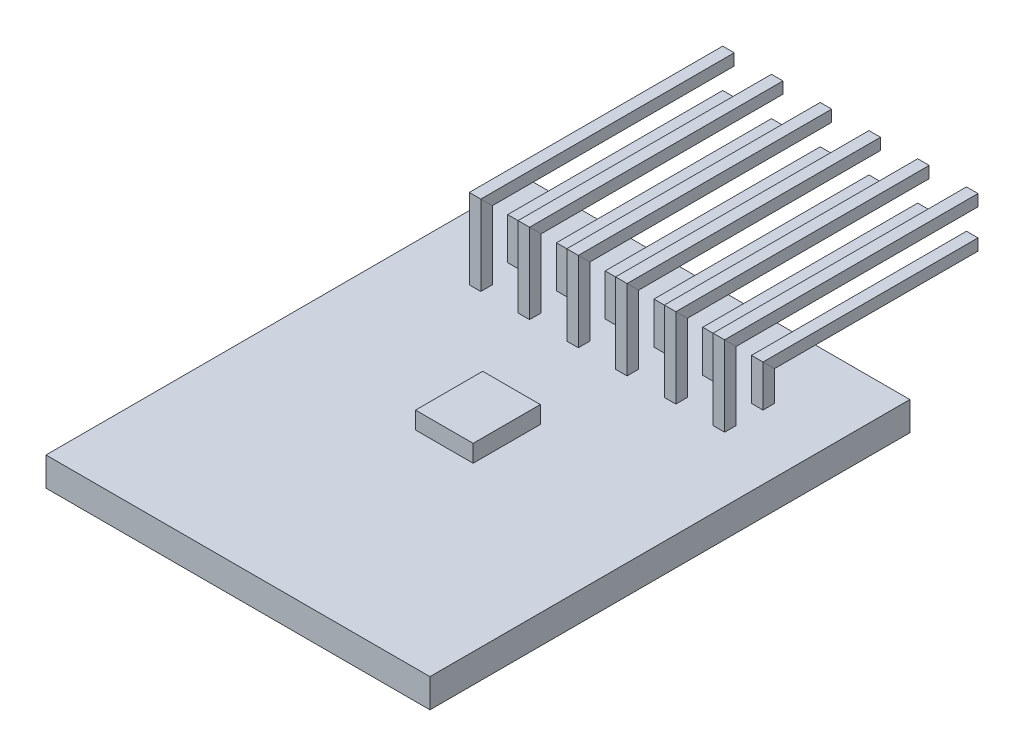
from build123d import *

# Parameters (mm, degrees)
SKETCH1_W                  = 20
SKETCH1_H                  = 25
BOSS_EXTRUDE1_DEPTH        = 1.5
SKETCH3_W                  = 0.6
SKETCH3_H                  = 0.6
CHAMFER1_SIZE              = 0.1
LPATTERN3_COUNT            = 6
LPATTERN3_PITCH            = 2.54
CHAMFER1_OF_LPATTERN3_SIZE = 0.1
SKETCH4_W                  = 3
SKETCH4_H                  = 3.5
BOSS_EXTRUDE2_DEPTH        = 0.9


with BuildPart() as part:
    # Sketch1 → Boss-Extrude1 (new body)
    with BuildSketch(Plane(origin=(0, 0, 0), x_dir=(1, 0, 0), z_dir=(0, 1, 0))):
        Rectangle(SKETCH1_W, SKETCH1_H)
    extrude(amount=BOSS_EXTRUDE1_DEPTH)

    # Sweep2: sweep along a path in Sketch2
    with BuildLine(Plane(origin=(6.35, 0, 0), x_dir=(0, 0, -1), z_dir=(1, 0, 0))) as sweep2_path:
        Line((8.5, -1), (8.5, 3.368980589))
        Line((8.5, 3.368980589), (19.5, 3.368980589))
    # Sketch3 → Sweep2 (sweep)
    with BuildSketch(Plane(origin=(0, 1.5, 0), x_dir=(1, 0, 0), z_dir=(0, 1, 0))):
        with Locations((6.35, 8.5)):
            Rectangle(SKETCH3_W, SKETCH3_H)
        with Locations((6.35, 6.5)):
            Rectangle(SKETCH3_W, SKETCH3_H)
    sweep2 = sweep(path=sweep2_path.line, transition=Transition.RIGHT)

    # Chamfer1
    chamfer1_edges = [part.edges().sort_by_distance(p)[0] for p in [
        (6.65, 3.368980589, -19.5),
        (6.35, 3.068980589, -19.5),
        (6.05, 3.368980589, -19.5),
        (6.35, 3.668980589, -19.5),
        (6.05, -1, -8.5),
        (6.35, -1, -8.2),
        (6.65, -1, -8.5),
        (6.35, -1, -8.8),
        (6.65, 5.368980589, -19.5),
        (6.35, 5.068980589, -19.5),
        (6.05, 5.368980589, -19.5),
        (6.35, 5.668980589, -19.5),
        (6.05, -1, -6.5),
        (6.35, -1, -6.2),
        (6.65, -1, -6.5),
        (6.35, -1, -6.8),
    ]]
    chamfer(chamfer1_edges, length=CHAMFER1_SIZE)

    # LPattern3: Sweep2 ×6
    with Locations(*[(-i * LPATTERN3_PITCH, 0, 0) for i in range(1, LPATTERN3_COUNT)]):
        add(sweep2)

    # Chamfer1 of LPattern3
    chamfer1_of_lpattern3_edges = [part.edges().sort_by_distance(p)[0] for p in [
        (4.11, 3.368980589, -19.5),
        (3.81, 3.068980589, -19.5),
        (3.51, 3.368980589, -19.5),
        (3.81, 3.668980589, -19.5),
        (3.51, -1, -8.5),
        (3.81, -1, -8.2),
        (4.11, -1, -8.5),
        (3.81, -1, -8.8),
        (4.11, 5.368980589, -19.5),
        (3.81, 5.068980589, -19.5),
        (3.51, 5.368980589, -19.5),
        (3.81, 5.668980589, -19.5),
        (3.51, -1, -6.5),
        (3.81, -1, -6.2),
        (4.11, -1, -6.5),
        (3.81, -1, -6.8),
        (1.57, 3.368980589, -19.5),
        (1.27, 3.068980589, -19.5),
        (0.97, 3.368980589, -19.5),
        (1.27, 3.668980589, -19.5),
        (0.97, -1, -8.5),
        (1.27, -1, -8.2),
        (1.57, -1, -8.5),
        (1.27, -1, -8.8),
        (1.57, 5.368980589, -19.5),
        (1.27, 5.068980589, -19.5),
        (0.97, 5.368980589, -19.5),
        (1.27, 5.668980589, -19.5),
        (0.97, -1, -6.5),
        (1.27, -1, -6.2),
        (1.57, -1, -6.5),
        (1.27, -1, -6.8),
        (-0.97, 3.368980589, -19.5),
        (-1.27, 3.068980589, -19.5),
        (-1.57, 3.368980589, -19.5),
        (-1.27, 3.668980589, -19.5),
        (-1.57, -1, -8.5),
        (-1.27, -1, -8.2),
        (-0.97, -1, -8.5),
        (-1.27, -1, -8.8),
        (-0.97, 5.368980589, -19.5),
        (-1.27, 5.068980589, -19.5),
        (-1.57, 5.368980589, -19.5),
        (-1.27, 5.668980589, -19.5),
        (-1.57, -1, -6.5),
        (-1.27, -1, -6.2),
        (-0.97, -1, -6.5),
        (-1.27, -1, -6.8),
        (-3.51, 3.368980589, -19.5),
        (-3.81, 3.068980589, -19.5),
        (-4.11, 3.368980589, -19.5),
        (-3.81, 3.668980589, -19.5),
        (-4.11, -1, -8.5),
        (-3.81, -1, -8.2),
        (-3.51, -1, -8.5),
        (-3.81, -1, -8.8),
        (-3.51, 5.368980589, -19.5),
        (-3.81, 5.068980589, -19.5),
        (-4.11, 5.368980589, -19.5),
        (-3.81, 5.668980589, -19.5),
        (-4.11, -1, -6.5),
        (-3.81, -1, -6.2),
        (-3.51, -1, -6.5),
        (-3.81, -1, -6.8),
        (-6.05, 3.368980589, -19.5),
        (-6.35, 3.068980589, -19.5),
        (-6.65, 3.368980589, -19.5),
        (-6.35, 3.668980589, -19.5),
        (-6.65, -1, -8.5),
        (-6.35, -1, -8.2),
        (-6.05, -1, -8.5),
        (-6.35, -1, -8.8),
        (-6.05, 5.368980589, -19.5),
        (-6.35, 5.068980589, -19.5),
        (-6.65, 5.368980589, -19.5),
        (-6.35, 5.668980589, -19.5),
        (-6.65, -1, -6.5),
        (-6.35, -1, -6.2),
        (-6.05, -1, -6.5),
        (-6.35, -1, -6.8),
    ]]
    chamfer(chamfer1_of_lpattern3_edges, length=CHAMFER1_OF_LPATTERN3_SIZE)

    # Sketch4 → Boss-Extrude2 (add)
    with BuildSketch(Plane(origin=(0, 1.5, 0), x_dir=(1, 0, 0), z_dir=(0, 1, 0))):
        Rectangle(SKETCH4_W, SKETCH4_H)
    extrude(amount=BOSS_EXTRUDE2_DEPTH)


solid = part.part
